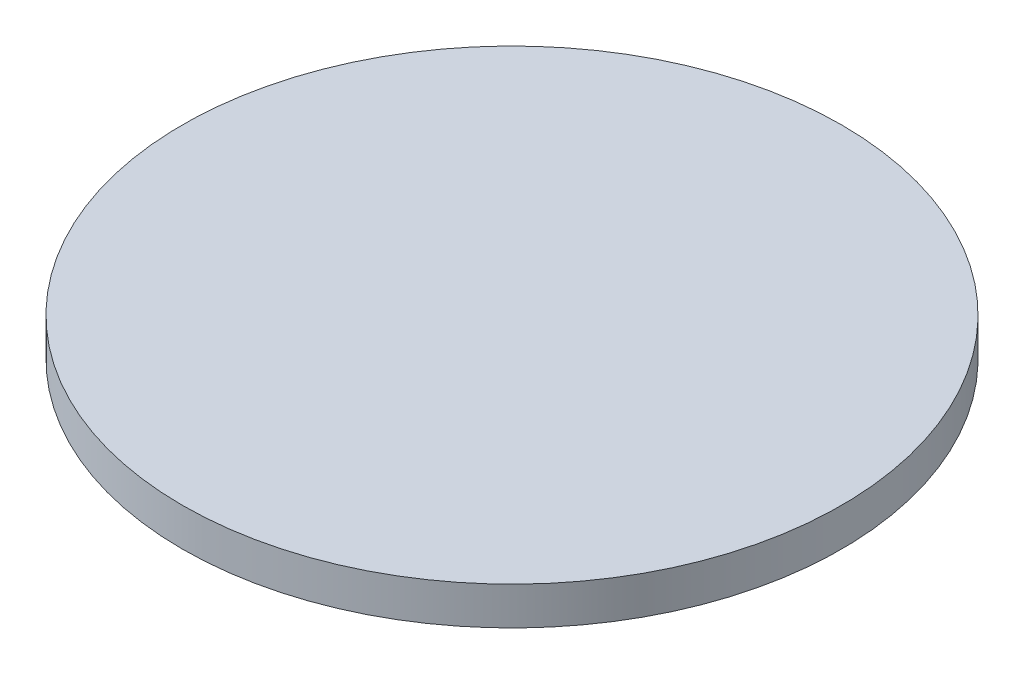
from build123d import *

# Parameters (mm, degrees)
SKETCH1_R           = 83.82
BOSS_EXTRUDE1_DEPTH = 4.826


with BuildPart() as part:
    # Sketch1 → Boss-Extrude1 (new body, symmetric)
    with BuildSketch(Plane(origin=(0, 0, 0), x_dir=(1, 0, 0), z_dir=(0, 1, 0))):
        Circle(SKETCH1_R)
    extrude(amount=BOSS_EXTRUDE1_DEPTH, both=True)


solid = part.part
